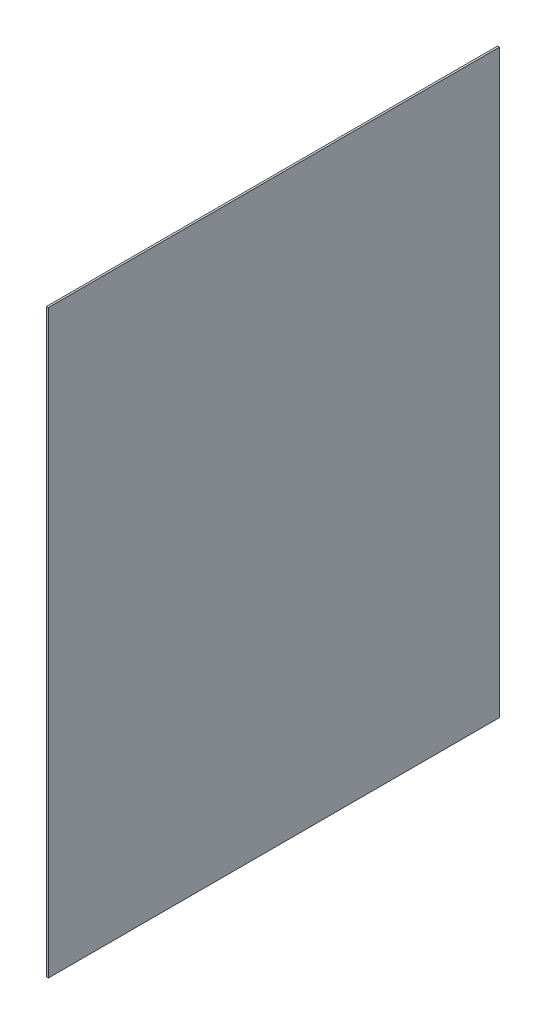
from build123d import *

# Parameters (mm, degrees)
CROQUIS1_W              = 23.3
CROQUIS1_H              = 30
SALIENTE_EXTRUIR1_DEPTH = 0.1


with BuildPart() as part:
    # Croquis1 → Saliente-Extruir1 (new body)
    with BuildSketch(Plane(origin=(0, 0, 0), x_dir=(0, 0, -1), z_dir=(1, 0, 0))):
        with Locations((11.65, 15)):
            Rectangle(CROQUIS1_W, CROQUIS1_H)
    extrude(amount=SALIENTE_EXTRUIR1_DEPTH)


solid = part.part
